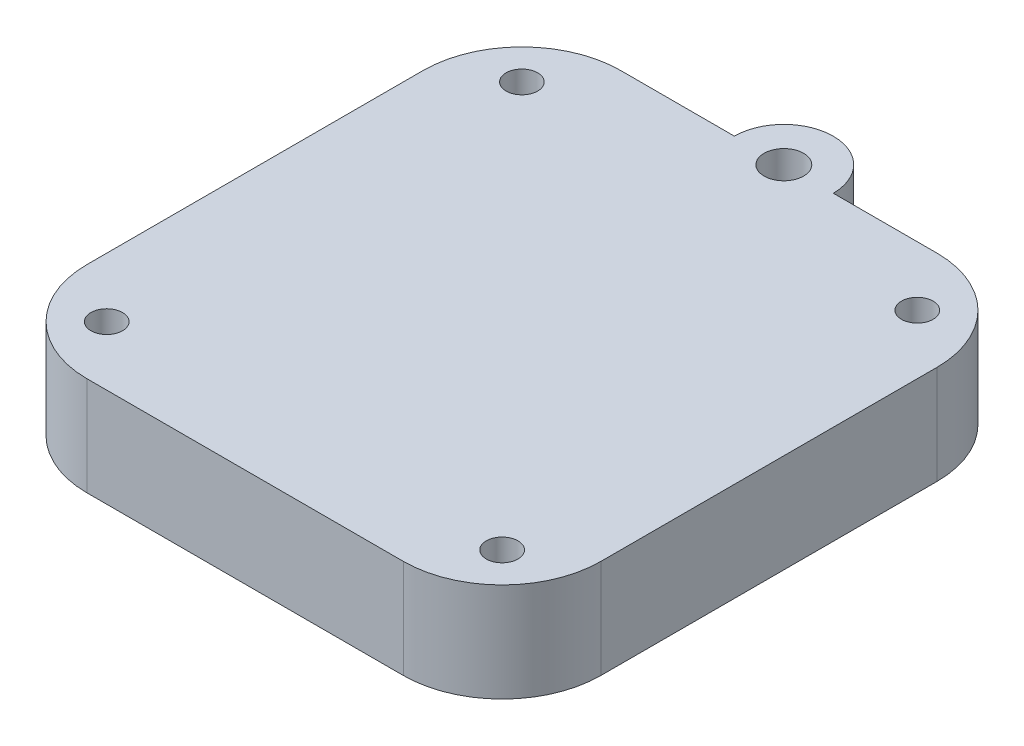
from build123d import *

# Parameters (mm, degrees)
SKETCH1_R           = 1.6
SKETCH1_R_2         = 2
BOSS_EXTRUDE1_DEPTH = 10
FILLET1_R           = 10
FILLET2_R           = 10
FILLET3_R           = 10
FILLET4_R           = 10


with BuildPart() as part:
    # Sketch1 → Boss-Extrude1 (new body)
    with BuildSketch(Plane(origin=(0, 0, 0), x_dir=(1, 0, 0), z_dir=(0, 1, 0))):
        with BuildLine():
            Line((-4.5, 27), (-26, 27))
            Line((-26, 27), (-26, -27))
            Line((-26, -27), (26, -27))
            Line((26, -27), (26, 27))
            Line((26, 27), (5.5, 27))
            ThreePointArc((5.5, 27), (0.5, 32), (-4.5, 27))
        make_face()
        with Locations(Location((-20, 21, 0), (0, 0, 270))):  # turned: the seam where the file's is
            Circle(SKETCH1_R, mode=Mode.SUBTRACT)
        with Locations(Location((20, 21, 0), (0, 0, 270))):  # turned: the seam where the file's is
            Circle(SKETCH1_R, mode=Mode.SUBTRACT)
        with Locations(Location((20, -21, 0), (0, 0, 270))):  # turned: the seam where the file's is
            Circle(SKETCH1_R, mode=Mode.SUBTRACT)
        with Locations(Location((-20, -21, 0), (0, 0, 270))):  # turned: the seam where the file's is
            Circle(SKETCH1_R, mode=Mode.SUBTRACT)
        with Locations(Location((0.5, 27, 0), (0, 0, 270))):  # turned: the seam where the file's is
            Circle(SKETCH1_R_2, mode=Mode.SUBTRACT)
    extrude(amount=BOSS_EXTRUDE1_DEPTH)

    # Fillet1
    fillet1_edges = [part.edges().sort_by_distance(p)[0] for p in [
        (-26, 5, -27),
    ]]
    fillet(fillet1_edges, radius=FILLET1_R)

    # Fillet2
    fillet2_edges = [part.edges().sort_by_distance(p)[0] for p in [
        (26, 5, -27),
    ]]
    fillet(fillet2_edges, radius=FILLET2_R)

    # Fillet3
    fillet3_edges = [part.edges().sort_by_distance(p)[0] for p in [
        (-26, 5, 27),
    ]]
    fillet(fillet3_edges, radius=FILLET3_R)

    # Fillet4
    fillet4_edges = [part.edges().sort_by_distance(p)[0] for p in [
        (26, 5, 27),
    ]]
    fillet(fillet4_edges, radius=FILLET4_R)


solid = part.part
